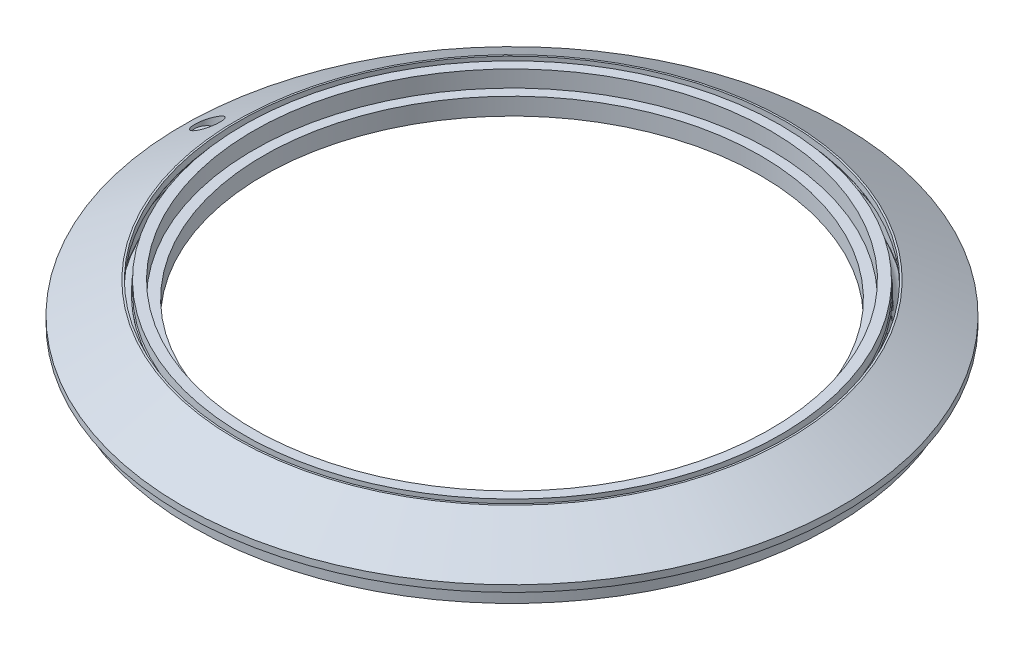
from build123d import *

# Parameters (mm, degrees)
CUT_EXTRUDE1_REACH = 143.611
SKETCH2_R          = 2
CUT_EXTRUDE5_START = -8
SKETCH2_3_R        = 3.8
CUT_EXTRUDE5_DEPTH = 10


with BuildPart() as part:
    # Sketch1 → Revolve1 (revolve)
    with BuildSketch(Plane.XY):
        with BuildLine():
            Line((-83.267949192, 16.350852961), (-99.464101615, 7))
            Line((-99.464101615, 7), (-99.464101615, 5))
            Line((-99.464101615, 5), (-96.464101615, 5))
            Line((-96.464101615, 5), (-96.464101615, 0))
            Line((-96.464101615, 0), (-87.464101615, 0))
            Line((-87.464101615, 0), (-87.464101615, 8.154700538))
            Line((-87.464101615, 8.154700538), (-85.732050808, 9.154700538))
            Line((-85.732050808, 9.154700538), (-85.482050808, 9.58771324))
            ThreePointArc((-85.482050808, 9.58771324), (-85.098076211, 12.25277675), (-82.982050808, 13.917840259))
            Line((-82.982050808, 13.917840259), (-82.732050808, 14.350852961))
            Line((-82.732050808, 14.350852961), (-82.732050808, 16.350852961))
            Line((-82.732050808, 16.350852961), (-83.267949192, 16.350852961))
        make_face()
    revolve(axis=Axis((0, 0, 0), (0, 1, 0)))

    # Sketch2 → Cut-Extrude1 (cut, up to next)
    with BuildSketch(Plane.XZ, mode=Mode.PRIVATE) as cut_extrude1_sk1:
        with Locations((-91.964101615, 0)):
            Circle(SKETCH2_R)
    cut_extrude1_tool1 = extrude(cut_extrude1_sk1.sketch, amount=-CUT_EXTRUDE1_REACH, mode=Mode.PRIVATE) & part.part
    add(cut_extrude1_tool1.solids().sort_by_distance((-91.964102, 0, 0))[0], mode=Mode.SUBTRACT)

    # Sketch2_3 → Cut-Extrude5 (cut)
    with BuildSketch(Plane.XZ.offset(CUT_EXTRUDE5_START)):
        with Locations((-91.964101615, 0)):
            Circle(SKETCH2_3_R)
    extrude(amount=-CUT_EXTRUDE5_DEPTH, mode=Mode.SUBTRACT)


with BuildPart() as body_2:
    # Sketch1_3 → Revolve2 (revolve)
    with BuildSketch(Plane.XY):
        with BuildLine():
            Line((-83.75, 8.58771324), (-84, 8.154700538))
            Line((-84, 8.154700538), (-84, 6.154700538))
            Line((-84, 6.154700538), (-75, 6.154700538))
            Line((-75, 6.154700538), (-75, 11.350852961))
            Line((-75, 11.350852961), (-77.8, 11.350852961))
            Line((-77.8, 11.350852961), (-78, 11.350852961))
            Line((-78, 11.350852961), (-78, 16.350852961))
            Line((-78, 16.350852961), (-81, 16.350852961))
            Line((-81, 16.350852961), (-81, 13.350852961))
            Line((-81, 13.350852961), (-81.25, 12.917840259))
            ThreePointArc((-81.25, 12.917840259), (-81.633974596, 10.25277675), (-83.75, 8.58771324))
        make_face()
    revolve(axis=Axis((0, 0, 0), (0, 1, 0)))


solid = Compound([part.part, body_2.part])
